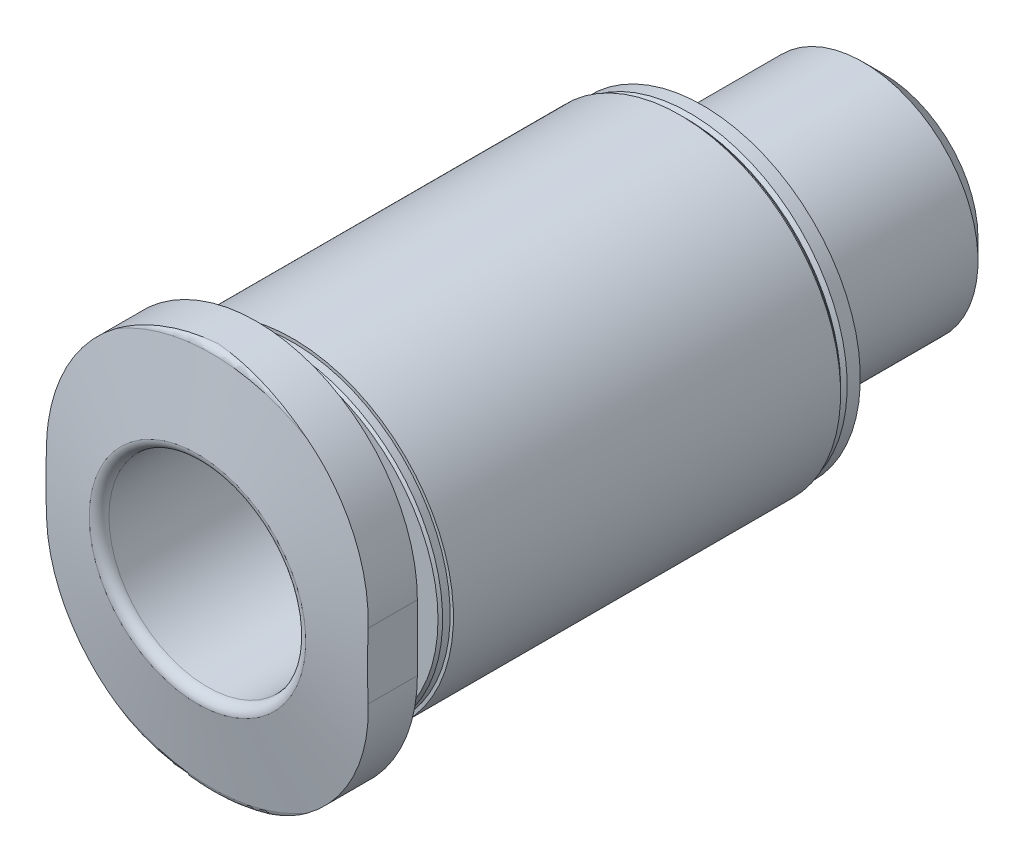
from build123d import *

# Parameters (mm, degrees)
CUT_EXTRUDE1_DEPTH = 8.9
SKETCH3_W          = 20
SKETCH3_H          = 20
CUT_EXTRUDE2_DEPTH = 2


with BuildPart() as part:
    # Sketch1 → Revolve1 (revolve)
    with BuildSketch(Plane(origin=(0, 0, 0), x_dir=(0, 0, -1), z_dir=(1, 0, 0))):
        with BuildLine():
            Line((-3.4, 0), (-3.4, 3))
            Line((-3.4, 3), (-15.1, 3))
            ThreePointArc((-15.1, 3), (-15.312132034, 3.087867966), (-15.4, 3.3))
            Line((-15.4, 3.3), (-14.970691475, 5.734729636))
            ThreePointArc((-14.970691475, 5.734729636), (-14.902287446, 5.853208889), (-14.773729924, 5.9))
            Line((-14.773729924, 5.9), (-13.6, 5.9))
            Line((-13.6, 5.9), (-13.6, 4.075))
            ThreePointArc((-13.6, 4.075), (-13.490165043, 3.809834957), (-13.225, 3.7))
            Line((-13.225, 3.7), (-12.8, 3.7))
            Line((-12.8, 3.7), (-12.8, 4.729289322))
            Line((-12.8, 4.729289322), (-12.729289322, 4.8))
            Line((-12.729289322, 4.8), (-12.5, 4.8))
            Line((-12.5, 4.8), (-12.5, 4.9))
            Line((-12.5, 4.9), (-0.7, 4.9))
            Line((-0.7, 4.9), (-0.7, 4.8))
            Line((-0.7, 4.8), (-0.6, 4.8))
            Line((-0.6, 4.8), (-0.5, 4.7))
            Line((-0.5, 4.7), (-0.4, 4.8))
            Line((-0.4, 4.8), (0, 4.8))
            Line((0, 4.8), (0, 3.5))
            Line((0, 3.5), (4.8865, 3.5))
            Line((4.8865, 3.5), (5.5, 2.8865))
            Line((5.5, 2.8865), (5.5, 0))
            Line((5.5, 0), (-3.4, 0))
        make_face()
    revolve(axis=Axis((0, 0, -5.5), (0, 0, 1)))

    # Sketch2 → Cut-Extrude1 (cut)
    with BuildSketch(Plane.XY.offset(-5.5)):
        Polygon((-2, -1.154700538), (0, -2.309401077), (2, -1.154700538), (2, 1.154700538), (0, 2.309401077), (-2, 1.154700538), align=None)
    extrude(amount=CUT_EXTRUDE1_DEPTH, mode=Mode.SUBTRACT)

    # Sketch3 → Cut-Extrude2 (cut)
    with BuildSketch(Plane.XY.offset(15.4)):
        Rectangle(SKETCH3_W, SKETCH3_H)
        with BuildLine():
            Line((-4.9, 1), (-4.9, -0.999999812))
            ThreePointArc((-4.9, -0.999999812), (0, -5.899999812), (4.9, -0.999999812))
            Line((4.9, -0.999999812), (4.9, 1))
            ThreePointArc((4.9, 1), (0, 5.9), (-4.9, 1))
        make_face(mode=Mode.SUBTRACT)
    extrude(amount=-CUT_EXTRUDE2_DEPTH, mode=Mode.SUBTRACT)


solid = part.part
